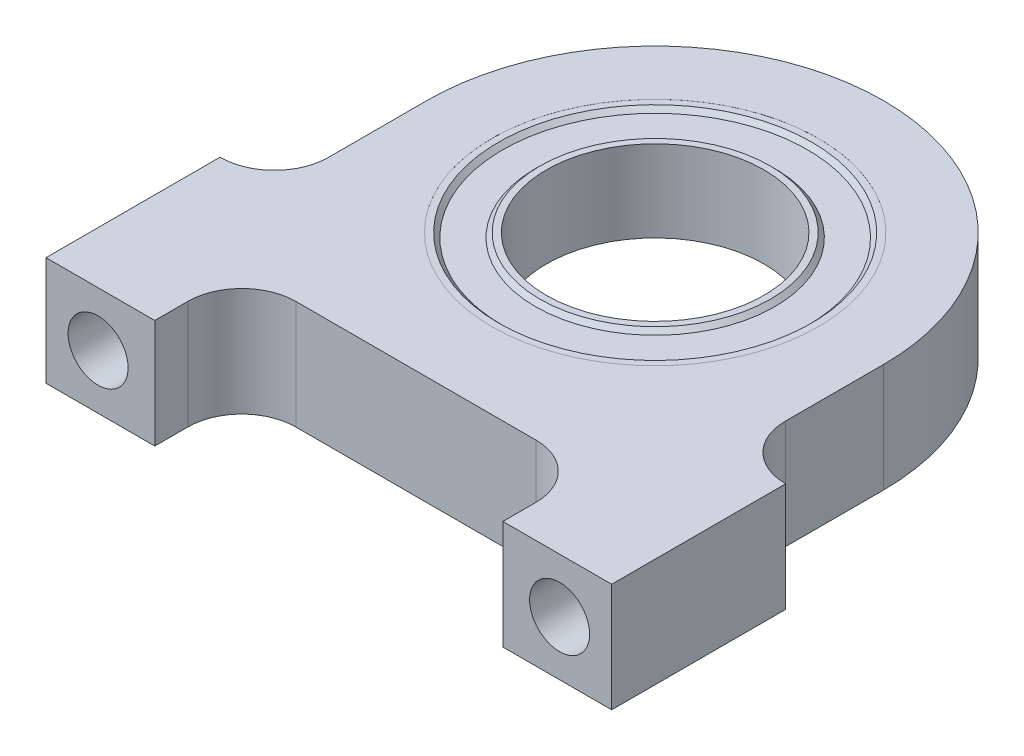
from build123d import *

# Parameters (mm, degrees)
SKETCH1_R                       = 8.73125
BOSS_EXTRUDE1_DEPTH             = 6.35
SKETCH2_R                       = 9.525
CUT_EXTRUDE1_DEPTH              = 4.7625
SKETCH3_R                       = 9.525
SKETCH3_R_2                     = 8.89
BOSS_EXTRUDE2_DEPTH             = 4.75996
CHAMFER1_SIZE                   = 0.254
SKETCH5_R                       = 6.985
SKETCH5_R_2                     = 6.35
BOSS_EXTRUDE3_DEPTH             = 4.75996
CHAMFER2_SIZE                   = 0.254
SKETCH6_R                       = 8.89
SKETCH6_R_2                     = 6.985
BOSS_EXTRUDE4_DEPTH             = 4.25196
F_6_32_TAPPED_HOLE1_D           = 2.7051
F_6_32_TAPPED_HOLE1_DEPTH       = 9.398
F_6_32_TAPPED_HOLE1_CBORE_D     = 3.5052
F_6_32_TAPPED_HOLE1_CBORE_DEPTH = 7.0104
F_6_32_TAPPED_HOLE1_TIP         = 0.81269403


with BuildPart() as part:
    # Sketch1 → Boss-Extrude1 (new body)
    with BuildSketch(Plane(origin=(0, 0, 0), x_dir=(1, 0, 0), z_dir=(0, 1, 0))):
        with BuildLine():
            Line((-13.335, 0), (-13.335, -5.7404))
            ThreePointArc((-13.335, -5.7404), (-14.257496482, -7.967503518), (-16.4846, -8.89))
            Line((-16.4846, -8.89), (-16.51, -8.89))
            Line((-16.51, -8.89), (-16.51, -19.05))
            Line((-16.51, -19.05), (-10.16, -19.05))
            Line((-10.16, -19.05), (-10.16, -17.1196))
            ThreePointArc((-10.16, -17.1196), (-9.237503518, -14.892496482), (-7.0104, -13.97))
            Line((-7.0104, -13.97), (7.0104, -13.97))
            ThreePointArc((7.0104, -13.97), (9.237503518, -14.892496482), (10.16, -17.1196))
            Line((10.16, -17.1196), (10.16, -19.05))
            Line((10.16, -19.05), (16.51, -19.05))
            Line((16.51, -19.05), (16.51, -8.89))
            Line((16.51, -8.89), (16.4846, -8.89))
            ThreePointArc((16.4846, -8.89), (14.257496482, -7.967503518), (13.335, -5.7404))
            Line((13.335, -5.7404), (13.335, 0))
            ThreePointArc((13.335, 0), (0, 13.335), (-13.335, 0))
        make_face()
        Circle(SKETCH1_R, mode=Mode.SUBTRACT)
    extrude(amount=BOSS_EXTRUDE1_DEPTH)

    # Sketch2 → Cut-Extrude1 (cut)
    with BuildSketch(Plane(origin=(0, 6.35, 0), x_dir=(1, 0, 0), z_dir=(0, 1, 0))):
        Circle(SKETCH2_R)
    extrude(amount=-CUT_EXTRUDE1_DEPTH, mode=Mode.SUBTRACT)

    # Sketch3 → Boss-Extrude2 (add)
    with BuildSketch(Plane(origin=(0, 1.5875, 0), x_dir=(-1, 0, 0), z_dir=(0, 1, 0))):
        Circle(SKETCH3_R)
        Circle(SKETCH3_R_2, mode=Mode.SUBTRACT)
    extrude(amount=BOSS_EXTRUDE2_DEPTH)

    # Chamfer1
    chamfer1_edges = [part.edges().sort_by_distance(p)[0] for p in [
        (8.89, 6.34746, 0),
    ]]
    chamfer(chamfer1_edges, length=CHAMFER1_SIZE)



with BuildPart() as body_2:
    # Sketch5 → Boss-Extrude3 (new body)
    with BuildSketch(Plane(origin=(0, 1.5875, 0), x_dir=(-1, 0, 0), z_dir=(0, 1, 0))):
        Circle(SKETCH5_R)
        Circle(SKETCH5_R_2, mode=Mode.SUBTRACT)
    extrude(amount=BOSS_EXTRUDE3_DEPTH)

    # Chamfer2
    chamfer2_edges = [body_2.edges().sort_by_distance(p)[0] for p in [
        (6.985, 1.5875, 0),
        (6.985, 6.34746, 0),
    ]]
    chamfer(chamfer2_edges, length=CHAMFER2_SIZE)


with BuildPart() as part_1:
    add(part.part)

    add(body_2.part)  # Boss-Extrude4 merges body 2
    # Sketch6 → Boss-Extrude4 (add)
    with BuildSketch(Plane(origin=(0, 6.09346, 0), x_dir=(-1, 0, 0), z_dir=(0, 1, 0))):
        Circle(SKETCH6_R)
        Circle(SKETCH6_R_2, mode=Mode.SUBTRACT)
    extrude(amount=-BOSS_EXTRUDE4_DEPTH)

    # #6-32 Tapped Hole1
    with Locations(Plane.XY.offset(19.05)):
        with Locations((-13.470384182, 3.175), (13.470384182, 3.175)):
            CounterBoreHole(F_6_32_TAPPED_HOLE1_D / 2, F_6_32_TAPPED_HOLE1_CBORE_D / 2, F_6_32_TAPPED_HOLE1_CBORE_DEPTH, depth=F_6_32_TAPPED_HOLE1_DEPTH)
            with Locations((0, 0, -(F_6_32_TAPPED_HOLE1_DEPTH + F_6_32_TAPPED_HOLE1_TIP / 2))):  # 118° drill point
                Cone(0, F_6_32_TAPPED_HOLE1_D / 2, F_6_32_TAPPED_HOLE1_TIP, mode=Mode.SUBTRACT)


solid = part_1.part
